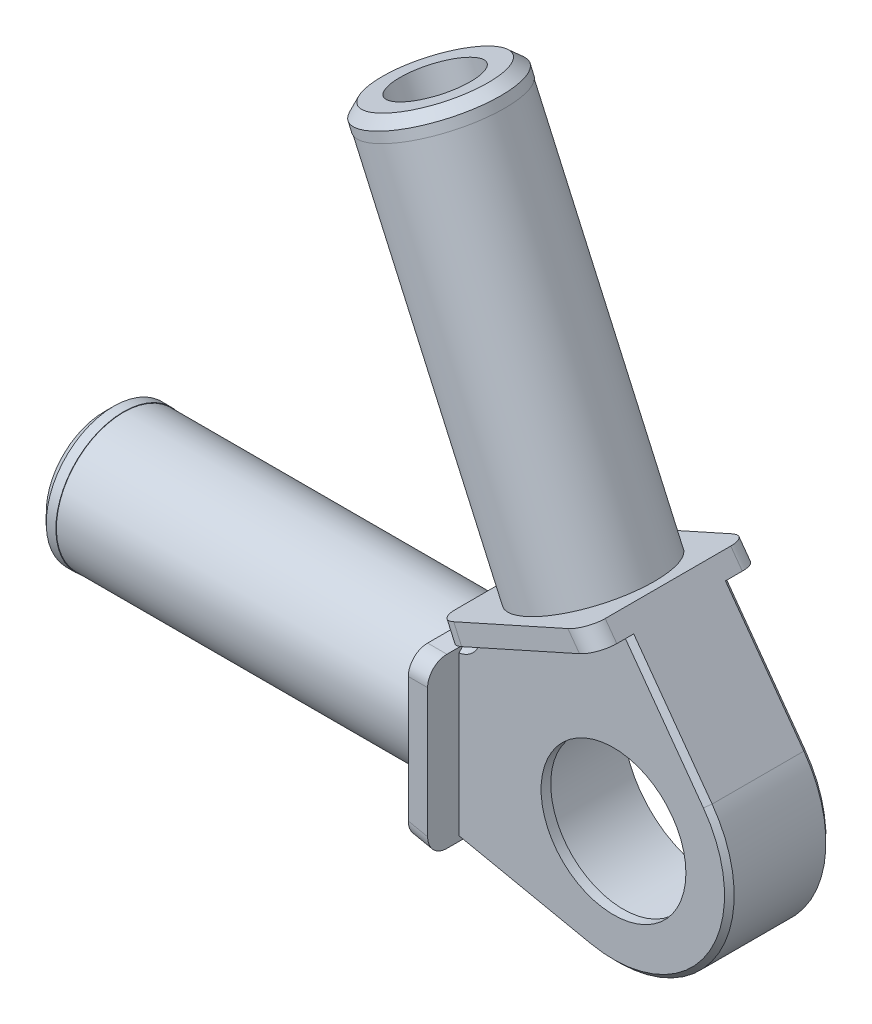
from build123d import *

# Parameters (mm, degrees)
SZKIC1_R                         = 9.5
DODANIE_WYCI_GNI_CIE1_DEPTH      = 10.5
DODANIE_WYCI_GNI_CIE2_START      = -1
SZKIC4_R                         = 9.5
SZKIC4_R_2                       = 7.5
DODANIE_WYCI_GNI_CIE2_DEPTH      = 1
DODANIE_WYCI_GNI_CIE5_DEPTH      = 3.25
DODANIE_WYCI_GNI_CIE5_DEPTH_BACK = 13.75
ZAOKR_GLENIE1_R                  = 2
SFAZOWANIE1_SIZE                 = 0.5
ZAOKR_GLENIE2_R                  = 0.5
SFAZOWANIE2_SIZE                 = 1
OTWORY_USTALAJ_CE_8_0MM4_D       = 8
OTWORY_USTALAJ_CE_8_0MM4_DEPTH   = 40
OTWORY_USTALAJ_CE_8_0MM4_TIP     = 2.403442476110241
OTWORY_USTALAJ_CE_8_0MM2_D       = 8
OTWORY_USTALAJ_CE_8_0MM2_DEPTH   = 40
OTWORY_USTALAJ_CE_8_0MM2_TIP     = 2.403442476110241


with BuildPart() as part:
    # Szkic1 → Dodanie-wyciągnięcie1 (new body)
    with BuildSketch(Plane.XY):
        with BuildLine():
            Line((-18, -8.500000000000002), (-2.452989835267137, -11.746609760610767))
            ThreePointArc((-2.452989835267137, -11.746609760610767), (10.072083256378775, -6.523276697839391), (9.716034523496084, 7.042632543178169))
            Line((9.716034523496084, 7.042632543178169), (0.3948872336267733, 19.902112050551786))
            Line((0.3948872336267733, 19.902112050551786), (-15.118317795339578, 12.949380951965187))
            Line((-15.118317795339578, 12.949380951965187), (-14.300349430799978, 11.124298007380911))
            ThreePointArc((-14.300349430799978, 11.124298007380911), (-14.606664802217058, 9.460139845161555), (-16, 8.499999999999996))
            Line((-16, 8.499999999999996), (-18, 8.499999999999998))
            Line((-18, 8.499999999999998), (-18, -8.500000000000002))
        make_face()
        with Locations(Location((0, 0, 0), (0, 0, 180))):
            Circle(SZKIC1_R, mode=Mode.SUBTRACT)
    extrude(amount=DODANIE_WYCI_GNI_CIE1_DEPTH)

    # Szkic2 → Obrót1 (revolve)
    with BuildSketch(Plane.XY.offset(5.25), mode=Mode.PRIVATE) as obr_t1_sk:
        Polygon((-57.99999999999999, -6.94e-15), (-57.99999999999999, -7.000000000000007), (-55.99999999999999, -7.000000000000007), (-55.99999999999999, -6.950000000000007), (-18.000000000000004, -6.950000000000007), (-18, -2.2e-15), align=None)
    revolve(obr_t1_sk.sketch.rotate(Axis((0, 0, 5.25), (-1, -1.2e-16, 0)), 180), axis=Axis((0, 0, 5.25), (-1, -1.2e-16, 0)))

    # Szkic3 → Obrót2 (revolve)
    with BuildSketch(Plane.XY.offset(5.25)):
        Polygon((-23.721082571648417, 52.927405392943996), (-17.333292265603436, 55.79029466883262), (-16.515323901063837, 53.96521172424835), (-16.560950974678434, 53.94476251513487), (-1.0195520484260303, 19.26818656803362), (-7.361715280856409, 16.425746501258498), align=None)
    revolve(axis=Axis((0, 0, 5.25), (-0.4089841822698003, 0.9125414722921379, 0)))

    # Szkic4 → Dodanie-wyciągnięcie2 (add)
    with BuildSketch(Plane.XY.offset(10.5).offset(DODANIE_WYCI_GNI_CIE2_START)):
        with Locations(Location((0, 0, 0), (0, 0, 180))):
            Circle(SZKIC4_R)
        Circle(SZKIC4_R_2, mode=Mode.SUBTRACT)
    extrude(amount=DODANIE_WYCI_GNI_CIE2_DEPTH)

    # Szkic8 → Dodanie-wyciągnięcie5 (add, two sides: drawn at the far end of the back side and taken through both)
    with BuildSketch(Plane.XY.offset(10.5).offset(-DODANIE_WYCI_GNI_CIE5_DEPTH_BACK)):
        Polygon((-18, 8.499999999999998), (-18, -8.500000000000002), (-15.999999999999996, -8.917650689902482), (-16, 8.499999999999996), align=None)
        Polygon((1.5939791736338076, 18.247841631851692), (0.3948872336267733, 19.902112050551786), (-15.118317795339578, 12.949380951965187), (-14.300349430799978, 11.124298007380911), align=None)
    extrude(amount=DODANIE_WYCI_GNI_CIE5_DEPTH + DODANIE_WYCI_GNI_CIE5_DEPTH_BACK)

    # Zaokrąglenie1
    zaokr_glenie1_edges = [part.edges().sort_by_distance(p)[0] for p in [
        (-17, -8.708825344951242, -3.25),
        (-17, 8.499999999999996, -3.25),
        (-17, 8.499999999999996, 13.75),
        (-17, -8.708825344951242, 13.75),
        (0.9944332036302904, 19.07497684120174, -3.25),
        (-14.709333613069777, 12.036839479673048, -3.25),
        (-14.709333613069777, 12.036839479673048, 13.75),
        (0.9944332036302904, 19.07497684120174, 13.75),
    ]]
    fillet(zaokr_glenie1_edges, radius=ZAOKR_GLENIE1_R)

    # Sfazowanie1
    sfazowanie1_edges = [part.edges().sort_by_distance(p)[0] for p in [
        (5.655006848564945, 12.645237087514932, 0),
        (10.072083256378772, -6.523276697839393, 0),
        (-14.606664802217058, 9.460139845161555, 10.5),
        (10.072083256378772, -6.523276697839393, 10.5),
        (-9.226494917633566, -10.332130225256623, 0),
        (-9.226494917633566, -10.332130225256623, 10.5),
        (5.655006848564945, 12.645237087514932, 10.5),
        (-14.606664802217058, 9.460139845161555, 0),
    ]]
    chamfer(sfazowanie1_edges, length=SFAZOWANIE1_SIZE)

    # Zaokrąglenie2
    zaokr_glenie2_edges = [part.edges().sort_by_distance(p)[0] for p in [
        (9.5, -2.33e-15, 9.5),
    ]]
    fillet(zaokr_glenie2_edges, radius=ZAOKR_GLENIE2_R)

    # Sfazowanie2
    sfazowanie2_edges = [part.edges().sort_by_distance(p)[0] for p in [
        (-57.99999999999999, -7.000000000000007, 5.249999999999998),
        (-30.108872877693408, 50.06451611705539, 5.249999999999999),
    ]]
    chamfer(sfazowanie2_edges, length=SFAZOWANIE2_SIZE)

    # Otwory ustalające Ø8.0mm4
    with Locations(Plane(origin=(-23.721082572, 52.927405393, 5.25), x_dir=(0.912541472292, 0.40898418227, 0), z_dir=(-0.40898418227, 0.912541472292, 0))):
        with Locations((0, 0)):
            Hole(OTWORY_USTALAJ_CE_8_0MM4_D / 2, depth=OTWORY_USTALAJ_CE_8_0MM4_DEPTH)
            with Locations((0, 0, -(OTWORY_USTALAJ_CE_8_0MM4_DEPTH + OTWORY_USTALAJ_CE_8_0MM4_TIP / 2))):  # 118° drill point
                Cone(0, OTWORY_USTALAJ_CE_8_0MM4_D / 2, OTWORY_USTALAJ_CE_8_0MM4_TIP, mode=Mode.SUBTRACT)

    # Otwory ustalające Ø8.0mm2
    with Locations(Plane(origin=(-58, 0, 5.25), x_dir=(0, -1, 0), z_dir=(-1, 0, 0))):
        with Locations((0, 0)):
            Hole(OTWORY_USTALAJ_CE_8_0MM2_D / 2, depth=OTWORY_USTALAJ_CE_8_0MM2_DEPTH)
            with Locations((0, 0, -(OTWORY_USTALAJ_CE_8_0MM2_DEPTH + OTWORY_USTALAJ_CE_8_0MM2_TIP / 2))):  # 118° drill point
                Cone(0, OTWORY_USTALAJ_CE_8_0MM2_D / 2, OTWORY_USTALAJ_CE_8_0MM2_TIP, mode=Mode.SUBTRACT)


solid = part.part
